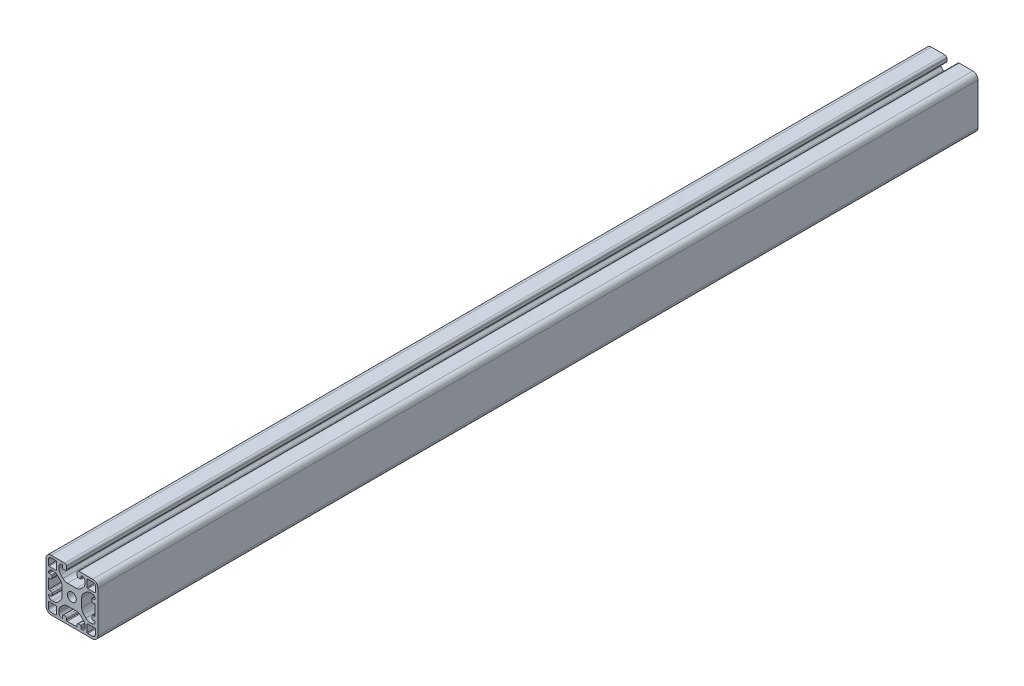
from build123d import *

# Parameters (mm, degrees)
SKIZZE1_R                       = 3.4
AUFSATZ_LINEAR_AUSTRAGEN1_DEPTH = 680


with BuildPart() as part:
    # Skizze1 → Aufsatz-Linear austragen1 (new body)
    with BuildSketch(Plane.XY.offset(680)):
        with BuildLine():
            Line((23.100000014, 35.850000004), (23.100000014, 37.500000007))
            ThreePointArc((23.100000014, 37.500000007), (23.246446625, 37.8535534), (23.600000018, 38.000000007))
            ThreePointArc((23.600000018, 38.000000007), (25.367766957, 37.267766953), (26.099999996, 35.500000007))
            Line((26.099999996, 35.500000007), (26.099999996, 34.292388137))
            ThreePointArc((26.099999996, 34.292388137), (25.719397659, 32.378970975), (24.635533902, 30.756854231))
            Line((24.635533902, 30.756854231), (22.943145774, 29.064466103))
            ThreePointArc((22.943145774, 29.064466103), (21.32102903, 27.980602346), (19.407611868, 27.600000008))
            Line((19.407611868, 27.600000008), (12.592388142, 27.600000008))
            ThreePointArc((12.592388142, 27.600000008), (10.678970981, 27.980602346), (9.056854237, 29.064466102))
            Line((9.056854237, 29.064466102), (7.36446608, 30.75685426))
            ThreePointArc((7.36446608, 30.75685426), (6.280602323, 32.378971004), (5.899999986, 34.292388165))
            Line((5.899999986, 34.292388165), (5.899999986, 35.500000003))
            ThreePointArc((5.899999986, 35.500000003), (6.632233037, 37.267766961), (8.399999999, 38.000000003))
            ThreePointArc((8.399999999, 38.000000003), (8.753553388, 37.853553393), (8.899999996, 37.500000003))
            Line((8.899999996, 37.500000003), (8.899999996, 35.850000004))
            ThreePointArc((8.899999996, 35.850000004), (9.046446605, 35.496446613), (9.399999996, 35.350000004))
            Line((9.399999996, 35.350000004), (10.899999944, 35.350000004))
            ThreePointArc((10.899999944, 35.350000004), (11.607106725, 35.642893223), (11.899999944, 36.350000004))
            Line((11.899999944, 36.350000004), (11.899999944, 38.500000016))
            ThreePointArc((11.899999944, 38.500000016), (11.460660115, 39.560660188), (10.399999943, 40.000000016))
            Line((10.399999943, 40.000000016), (4.8e-08, 40.000000016))
            ThreePointArc((4.8e-08, 40.000000016), (-2.828427121, 38.828427123), (-4.000000014, 35.999999954))
            Line((-4.000000014, 35.999999954), (-4.000000014, 4.000000069))
            ThreePointArc((-4.000000014, 4.000000069), (-2.828427124, 1.171572908), (3.7e-08, 1.8e-08))
            Line((3.7e-08, 1.8e-08), (31.999999922, 1.8e-08))
            ThreePointArc((31.999999922, 1.8e-08), (34.828427083, 1.171572908), (35.999999974, 4.000000069))
            Line((35.999999974, 4.000000069), (35.999999974, 35.999999953))
            ThreePointArc((35.999999974, 35.999999953), (34.82842708, 38.828427122), (31.99999991, 40.000000016))
            Line((31.99999991, 40.000000016), (21.599999961, 40.000000016))
            ThreePointArc((21.599999961, 40.000000016), (20.53933979, 39.560660188), (20.099999962, 38.500000017))
            Line((20.099999962, 38.500000017), (20.099999962, 36.350000004))
            ThreePointArc((20.099999962, 36.350000004), (20.392893181, 35.642893223), (21.099999962, 35.350000004))
            Line((21.099999962, 35.350000004), (22.600000014, 35.350000004))
            ThreePointArc((22.600000014, 35.350000004), (22.953553405, 35.496446613), (23.100000014, 35.850000004))
        make_face()
        with Locations((15.999999985, 20)):
            Circle(SKIZZE1_R, mode=Mode.SUBTRACT)
        with BuildLine():
            Line((4.8e-08, 38.200000033), (3.699999945, 38.200000033))
            ThreePointArc((3.699999945, 38.200000033), (4.053553343, 38.053553421), (4.199999956, 37.700000022))
            Line((4.199999956, 37.700000022), (4.199999956, 32.299999708))
            ThreePointArc((4.199999956, 32.299999708), (4.053553442, 31.946446549), (3.700000282, 31.800000035))
            Line((3.700000282, 31.800000035), (-1.70000008, 31.800000035))
            ThreePointArc((-1.70000008, 31.800000035), (-2.053553436, 31.94644663), (-2.200000031, 32.299999986))
            Line((-2.200000031, 32.299999986), (-2.200000031, 35.999999954))
            ThreePointArc((-2.200000031, 35.999999954), (-1.555634927, 37.555634929), (4.8e-08, 38.200000033))
        make_face(mode=Mode.SUBTRACT)
        with BuildLine():
            Line((-2.200000031, 4.000000069), (-2.200000031, 7.699999986))
            ThreePointArc((-2.200000031, 7.699999986), (-2.053553419, 8.053553385), (-1.70000002, 8.199999998))
            Line((-1.70000002, 8.199999998), (3.700000282, 8.199999998))
            ThreePointArc((3.700000282, 8.199999998), (4.053553442, 8.053553484), (4.199999956, 7.700000324))
            Line((4.199999956, 7.700000324), (4.199999956, 2.299999952))
            ThreePointArc((4.199999956, 2.299999952), (4.053553361, 1.946446596), (3.700000004, 1.800000001))
            Line((3.700000004, 1.800000001), (3.7e-08, 1.800000001))
            ThreePointArc((3.7e-08, 1.800000001), (-1.55563493, 2.444365102), (-2.200000031, 4.000000069))
        make_face(mode=Mode.SUBTRACT)
        with BuildLine():
            Line((31.999999922, 1.800000001), (28.300000004, 1.800000001))
            ThreePointArc((28.300000004, 1.800000001), (27.946446606, 1.946446613), (27.799999993, 2.300000012))
            Line((27.799999993, 2.300000012), (27.799999993, 7.700000324))
            ThreePointArc((27.799999993, 7.700000324), (27.946446507, 8.053553484), (28.299999667, 8.199999998))
            Line((28.299999667, 8.199999998), (33.700000039, 8.199999998))
            ThreePointArc((33.700000039, 8.199999998), (34.053553395, 8.053553402), (34.199999991, 7.700000046))
            Line((34.199999991, 7.700000046), (34.199999991, 4.000000069))
            ThreePointArc((34.199999991, 4.000000069), (33.555634889, 2.444365102), (31.999999922, 1.800000001))
        make_face(mode=Mode.SUBTRACT)
        with BuildLine():
            Line((34.199999991, 35.999999953), (34.199999991, 32.300000046))
            ThreePointArc((34.199999991, 32.300000046), (34.053553378, 31.946446648), (33.699999979, 31.800000035))
            Line((33.699999979, 31.800000035), (28.299999667, 31.800000035))
            ThreePointArc((28.299999667, 31.800000035), (27.946446507, 31.946446549), (27.799999993, 32.299999708))
            Line((27.799999993, 32.299999708), (27.799999993, 37.700000082))
            ThreePointArc((27.799999993, 37.700000082), (27.946446588, 38.053553438), (28.299999945, 38.200000033))
            Line((28.299999945, 38.200000033), (31.99999991, 38.200000033))
            ThreePointArc((31.99999991, 38.200000033), (33.555634886, 37.555634928), (34.199999991, 35.999999953))
        make_face(mode=Mode.SUBTRACT)
        with BuildLine():
            Line((12.592388143, 12.399999997), (19.407611847, 12.399999997))
            ThreePointArc((19.407611847, 12.399999997), (21.321029009, 12.01939766), (22.943145752, 10.935533904))
            Line((22.943145752, 10.935533904), (24.635533902, 9.243145754))
            ThreePointArc((24.635533902, 9.243145754), (25.719397659, 7.62102901), (26.099999996, 5.707611848))
            Line((26.099999996, 5.707611848), (26.099999996, 4.499999993))
            ThreePointArc((26.099999996, 4.499999993), (25.367766957, 2.732233048), (23.600000018, 1.999999995))
            ThreePointArc((23.600000018, 1.999999995), (23.246446625, 2.146446603), (23.100000014, 2.499999995))
            Line((23.100000014, 2.499999995), (23.100000014, 4.149999994))
            ThreePointArc((23.100000014, 4.149999994), (22.953553405, 4.503553383), (22.600000016, 4.649999992))
            Line((22.600000016, 4.649999992), (21.099999962, 4.649999992))
            ThreePointArc((21.099999962, 4.649999992), (20.392893181, 4.357106773), (20.099999962, 3.649999992))
            Line((20.099999962, 3.649999992), (20.099999962, 2.500000006))
            ThreePointArc((20.099999962, 2.500000006), (19.953553353, 2.146446616), (19.599999962, 2.000000006))
            Line((19.599999962, 2.000000006), (12.399999942, 2.000000006))
            ThreePointArc((12.399999942, 2.000000006), (12.046446553, 2.146446615), (11.899999944, 2.500000005))
            Line((11.899999944, 2.500000005), (11.899999944, 3.649999992))
            ThreePointArc((11.899999944, 3.649999992), (11.607106725, 4.357106773), (10.899999943, 4.649999992))
            Line((10.899999943, 4.649999992), (9.399999996, 4.649999992))
            ThreePointArc((9.399999996, 4.649999992), (9.046446606, 4.503553382), (8.899999996, 4.149999992))
            Line((8.899999996, 4.149999992), (8.899999996, 2.499999991))
            ThreePointArc((8.899999996, 2.499999991), (8.753553389, 2.146446604), (8.400000003, 1.999999994))
            ThreePointArc((8.400000003, 1.999999994), (6.632233039, 2.732233035), (5.899999986, 4.499999994))
            Line((5.899999986, 4.499999994), (5.899999986, 5.707611838))
            ThreePointArc((5.899999986, 5.707611838), (6.280602323, 7.621029001), (7.36446608, 9.243145746))
            Line((7.36446608, 9.243145746), (9.056854238, 10.935533903))
            ThreePointArc((9.056854238, 10.935533903), (10.678970982, 12.01939766), (12.592388143, 12.399999997))
        make_face(mode=Mode.SUBTRACT)
        with BuildLine():
            Line((-0.350000011, 15.899999977), (-1.500000012, 15.899999977))
            ThreePointArc((-1.500000012, 15.899999977), (-1.853553403, 16.046446586), (-2.000000012, 16.399999977))
            Line((-2.000000012, 16.399999977), (-2.000000012, 23.599999997))
            ThreePointArc((-2.000000012, 23.599999997), (-1.853553403, 23.953553386), (-1.500000014, 24.099999995))
            Line((-1.500000014, 24.099999995), (-0.350000011, 24.099999995))
            ThreePointArc((-0.350000011, 24.099999995), (0.35710677, 24.392893214), (0.649999989, 25.099999995))
            Line((0.649999989, 25.099999995), (0.649999989, 26.599999997))
            ThreePointArc((0.649999989, 26.599999997), (0.503553379, 26.953553388), (0.149999989, 27.099999997))
            Line((0.149999989, 27.099999997), (-1.500000012, 27.099999997))
            ThreePointArc((-1.500000012, 27.099999997), (-1.853553399, 27.246446604), (-2.000000009, 27.599999991))
            ThreePointArc((-2.000000009, 27.599999991), (-1.267766968, 29.367766955), (0.499999991, 30.100000008))
            Line((0.499999991, 30.100000008), (1.707611836, 30.100000008))
            ThreePointArc((1.707611836, 30.100000008), (3.621028998, 29.71939767), (5.243145743, 28.635533913))
            Line((5.243145743, 28.635533913), (6.935533893, 26.943145763))
            ThreePointArc((6.935533893, 26.943145763), (8.01939765, 25.321029019), (8.399999987, 23.407611857))
            Line((8.399999987, 23.407611857), (8.399999987, 16.592388128))
            ThreePointArc((8.399999987, 16.592388128), (8.01939765, 14.678970966), (6.935533894, 13.056854223))
            Line((6.935533894, 13.056854223), (5.243145736, 11.364466065))
            ThreePointArc((5.243145736, 11.364466065), (3.621028992, 10.280602309), (1.70761183, 9.899999971))
            Line((1.70761183, 9.899999971), (0.49999999, 9.899999971))
            ThreePointArc((0.49999999, 9.899999971), (-1.267766966, 10.632233022), (-2.000000008, 12.399999982))
            ThreePointArc((-2.000000008, 12.399999982), (-1.853553397, 12.753553371), (-1.500000008, 12.899999979))
            Line((-1.500000008, 12.899999979), (0.149999991, 12.899999979))
            ThreePointArc((0.149999991, 12.899999979), (0.50355338, 13.046446588), (0.649999989, 13.399999977))
            Line((0.649999989, 13.399999977), (0.649999989, 14.899999976))
            ThreePointArc((0.649999989, 14.899999976), (0.35710677, 15.607106758), (-0.350000011, 15.899999977))
        make_face(mode=Mode.SUBTRACT)
        with BuildLine():
            Line((23.599999999, 16.592388152), (23.599999999, 23.407611854))
            ThreePointArc((23.599999999, 23.407611854), (23.980602337, 25.321029015), (25.064466093, 26.943145759))
            Line((25.064466093, 26.943145759), (26.756854248, 28.635533914))
            ThreePointArc((26.756854248, 28.635533914), (28.378970992, 29.71939767), (30.292388154, 30.100000008))
            Line((30.292388154, 30.100000008), (31.49999999, 30.100000008))
            ThreePointArc((31.49999999, 30.100000008), (33.267766947, 29.367766956), (33.999999988, 27.599999994))
            ThreePointArc((33.999999988, 27.599999994), (33.853553377, 27.246446605), (33.499999988, 27.099999997))
            Line((33.499999988, 27.099999997), (31.849999989, 27.099999997))
            ThreePointArc((31.849999989, 27.099999997), (31.4964466, 26.953553388), (31.349999991, 26.6))
            Line((31.349999991, 26.6), (31.349999991, 25.099999995))
            ThreePointArc((31.349999991, 25.099999995), (31.64289321, 24.392893214), (32.349999991, 24.099999995))
            Line((32.349999991, 24.099999995), (33.499999986, 24.099999995))
            ThreePointArc((33.499999986, 24.099999995), (33.853553377, 23.953553386), (33.999999986, 23.599999995))
            Line((33.999999986, 23.599999995), (33.999999986, 16.399999975))
            ThreePointArc((33.999999986, 16.399999975), (33.853553377, 16.046446586), (33.499999988, 15.899999977))
            Line((33.499999988, 15.899999977), (32.349999991, 15.899999977))
            ThreePointArc((32.349999991, 15.899999977), (31.64289321, 15.607106758), (31.349999991, 14.899999977))
            Line((31.349999991, 14.899999977), (31.349999991, 13.39999998))
            ThreePointArc((31.349999991, 13.39999998), (31.496446601, 13.046446589), (31.849999991, 12.899999979))
            Line((31.849999991, 12.899999979), (33.499999992, 12.899999979))
            ThreePointArc((33.499999992, 12.899999979), (33.85355338, 12.753553372), (33.999999989, 12.399999985))
            ThreePointArc((33.999999989, 12.399999985), (33.267766947, 10.632233023), (31.499999989, 9.899999971))
            Line((31.499999989, 9.899999971), (30.292388181, 9.899999971))
            ThreePointArc((30.292388181, 9.899999971), (28.378971018, 10.280602309), (26.756854273, 11.364466066))
            Line((26.756854273, 11.364466066), (25.064466093, 13.056854246))
            ThreePointArc((25.064466093, 13.056854246), (23.980602337, 14.67897099), (23.599999999, 16.592388152))
        make_face(mode=Mode.SUBTRACT)
    extrude(amount=-AUFSATZ_LINEAR_AUSTRAGEN1_DEPTH)


solid = part.part
